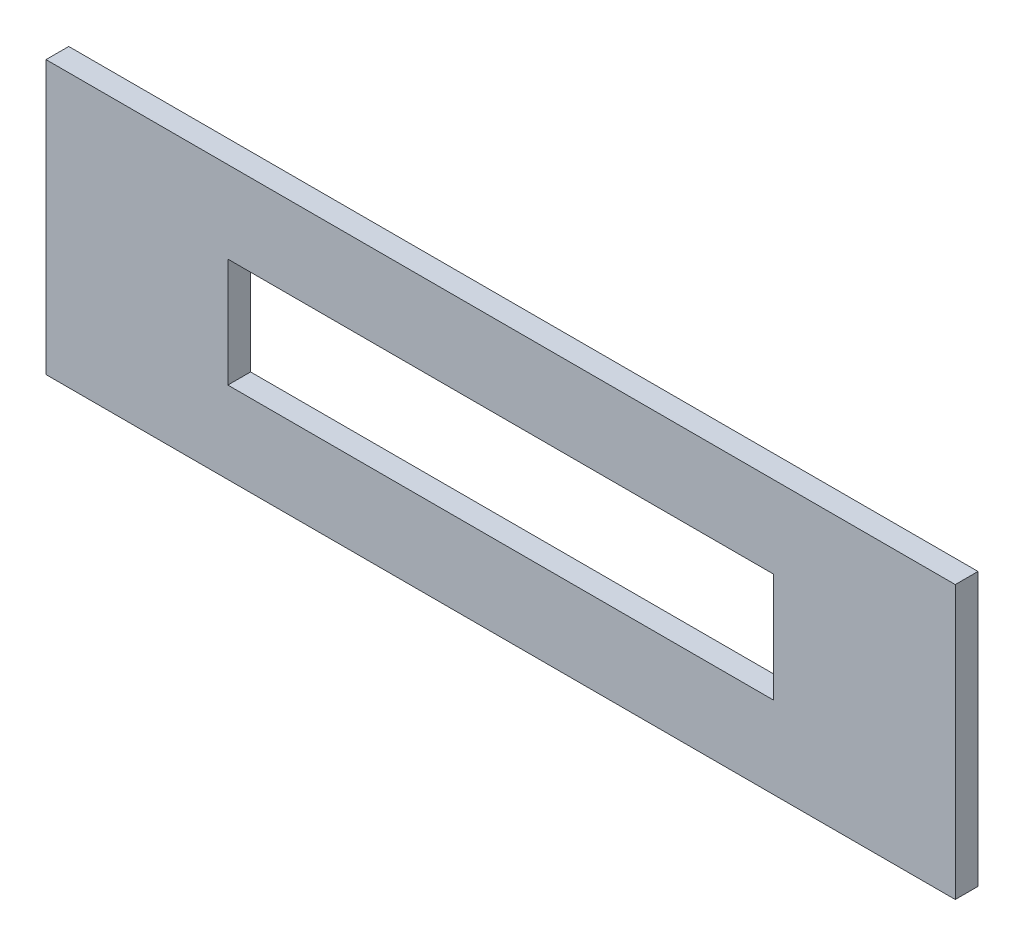
from build123d import *

# Parameters (mm, degrees)
SKETCH1_W           = 400
SKETCH1_H           = 120
SKETCH1_W_2         = 240
SKETCH1_H_2         = 48
BOSS_EXTRUDE1_DEPTH = 10


with BuildPart() as part:
    # Sketch1 → Boss-Extrude1 (new body)
    with BuildSketch(Plane.XY):
        Rectangle(SKETCH1_W, SKETCH1_H)
        Rectangle(SKETCH1_W_2, SKETCH1_H_2, mode=Mode.SUBTRACT)
    extrude(amount=BOSS_EXTRUDE1_DEPTH)


solid = part.part
